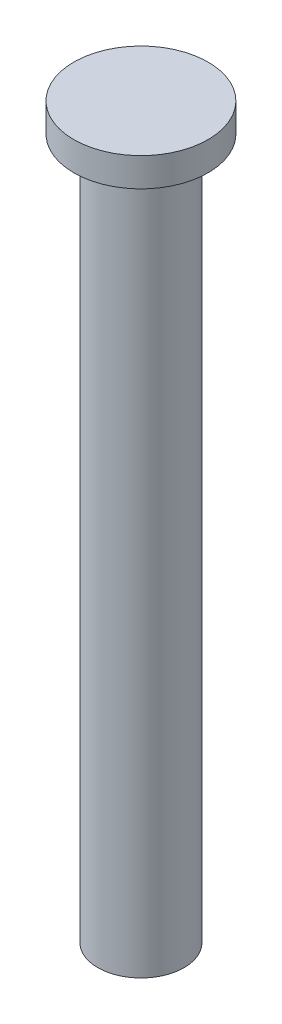
from build123d import *


with BuildPart() as part:
    # Sketch3 → Revolve1 (revolve)
    with BuildSketch(Plane.XY):
        Polygon((22.5, 0), (0, 0), (0, 380), (35, 380), (35, 365), (22.5, 365), align=None)
    revolve(axis=Axis((0, 314.585289515, 0), (0, -1, 0)))


solid = part.part
